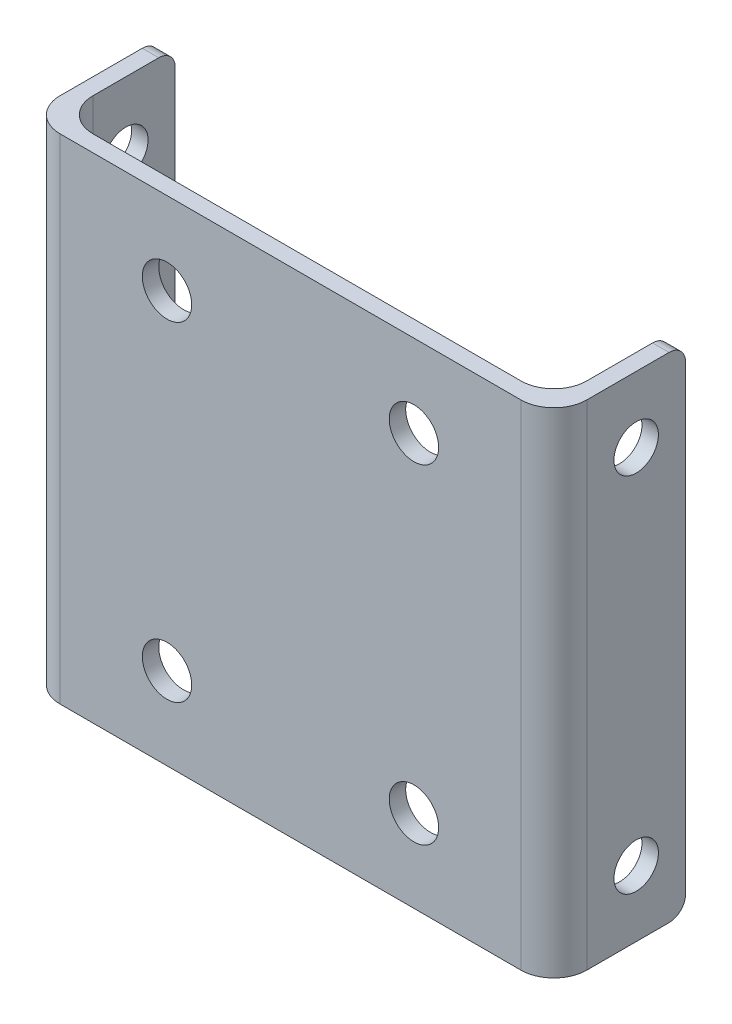
from build123d import *

# Parameters (mm, degrees)
BOSS_EXTRUDE1_DEPTH = 30
FILLET2_R           = 2
SKETCH3_R           = 1.5
CUT_EXTRUDE4_DEPTH  = 9
SKETCH4_R           = 1.35
CUT_EXTRUDE3_DEPTH  = 33
FILLET3_R           = 1


with BuildPart() as part:
    # Sketch1 → Boss-Extrude1 (new body)
    with BuildSketch(Plane(origin=(0, 0, 0), x_dir=(1, 0, 0), z_dir=(0, 1, 0))):
        Polygon((-21.5, 0.5), (8.5, 0.5), (8.5, 7.5), (9.5, 7.5), (9.5, 0.5), (9.5, -0.5), (-22.5, -0.5), (-22.5, 0.5), (-22.5, 7.5), (-21.5, 7.5), align=None)
    extrude(amount=BOSS_EXTRUDE1_DEPTH)

    # Fillet2
    fillet2_edges = [part.edges().sort_by_distance(p)[0] for p in [
        (9.5, 15, 0.5),
        (-22.5, 15, 0.5),
        (-21.5, 15, -0.5),
        (8.5, 15, -0.5),
    ]]
    fillet(fillet2_edges, radius=FILLET2_R)

    # Sketch3 → Cut-Extrude4 (cut, through all)
    with BuildSketch(Plane.XY.offset(0.5)):
        with Locations((-14, 25)):
            Circle(SKETCH3_R)
        with Locations((1, 25)):
            Circle(SKETCH3_R)
        with Locations((-14, 5)):
            Circle(SKETCH3_R)
        with Locations((1, 5)):
            Circle(SKETCH3_R)
    extrude(amount=-CUT_EXTRUDE4_DEPTH, mode=Mode.SUBTRACT)

    # Sketch4 → Cut-Extrude3 (cut, through all)
    with BuildSketch(Plane(origin=(9.5, 0, 0), x_dir=(0, 0, -1), z_dir=(1, 0, 0))):
        with Locations((4.5, 26)):
            Circle(SKETCH4_R)
        with Locations((4.5, 4)):
            Circle(SKETCH4_R)
    extrude(amount=-CUT_EXTRUDE3_DEPTH, mode=Mode.SUBTRACT)

    # Fillet3
    fillet3_edges = [part.edges().sort_by_distance(p)[0] for p in [
        (9, 30, -7.5),
        (-22, 0, -7.5),
        (9, 0, -7.5),
        (-22, 30, -7.5),
    ]]
    fillet(fillet3_edges, radius=FILLET3_R)


solid = part.part
